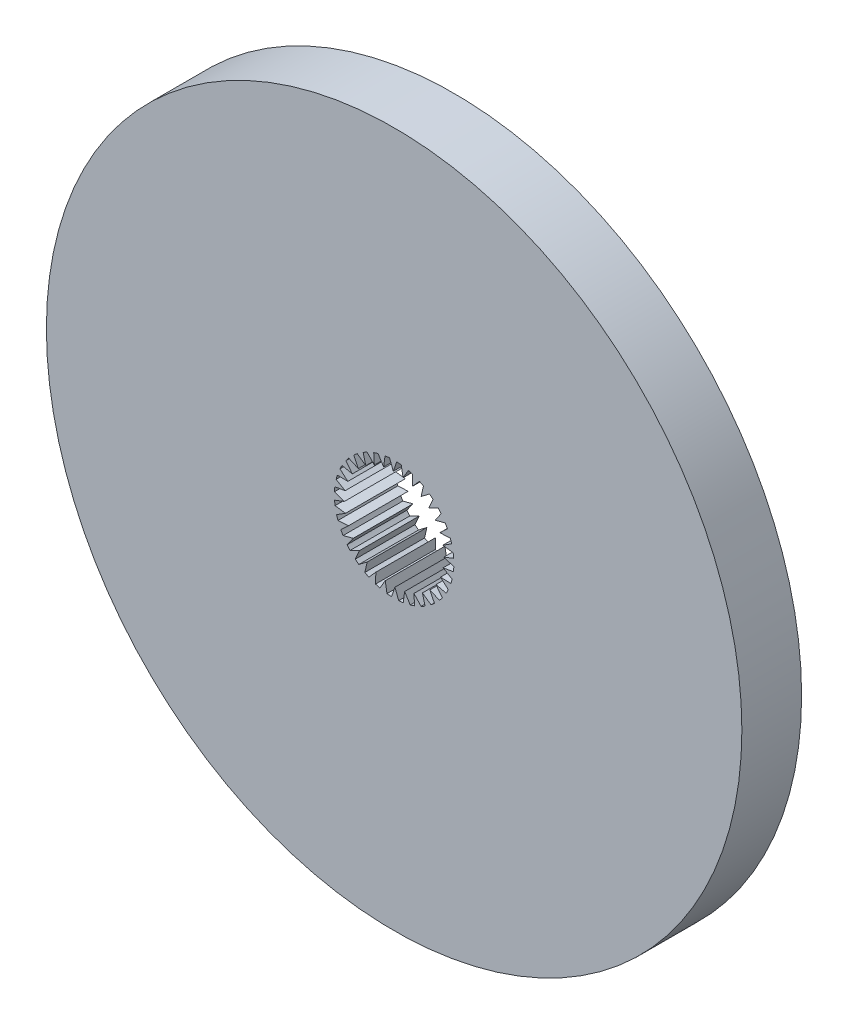
from build123d import *

# Parameters (mm, degrees)
SKETCH1_R          = 17.4625
EXTRUDE1_DEPTH     = 3
CUT_EXTRUDE2_DEPTH = 3


with BuildPart() as part:
    # Sketch1 → Extrude1 (new body)
    with BuildSketch(Plane.XY):
        Circle(SKETCH1_R)
    extrude(amount=EXTRUDE1_DEPTH)

    # Sketch4 → Cut-Extrude2 (cut)
    with BuildSketch(Plane(origin=(0, 0, 0), x_dir=(-1, 0, 0), z_dir=(0, 0, -1))):
        with BuildLine():
            Line((2.991248958, -0.228975264), (2.499665549, -0.040891873))
            Line((2.499665549, -0.040891873), (2.997137961, 0.131011615))
            ThreePointArc((2.997137961, 0.131011615), (2.989964496, 0.245178122), (2.978443806, 0.358988154))
            Line((2.978443806, 0.358988154), (2.459612785, 0.44755441))
            Line((2.459612785, 0.44755441), (2.913989697, 0.713206874))
            ThreePointArc((2.913989697, 0.713206874), (2.884681288, 0.823780229), (2.851178729, 0.933155859))
            Line((2.851178729, 0.933155859), (2.325038481, 0.918801427))
            Line((2.325038481, 0.918801427), (2.718858444, 1.267993992))
            ThreePointArc((2.718858444, 1.267993992), (2.668541396, 1.370724924), (2.614344452, 1.471462907))
            Line((2.614344452, 1.471462907), (2.101114252, 1.354739421))
            Line((2.101114252, 1.354739421), (2.419242985, 1.774052812))
            ThreePointArc((2.419242985, 1.774052812), (2.349850954, 1.86499343), (2.277042384, 1.953222461))
            Line((2.277042384, 1.953222461), (1.796445381, 1.738615539))
            Line((1.796445381, 1.738615539), (2.026657375, 2.211935778))
            ThreePointArc((2.026657375, 2.211935778), (1.940857058, 2.287591283), (1.852234854, 2.359920771))
            Line((1.852234854, 2.359920771), (1.422740121, 2.055677637))
            Line((1.422740121, 2.055677637), (1.556188458, 2.564815292))
            ThreePointArc((1.556188458, 2.564815292), (1.457277114, 2.622278287), (1.356246978, 2.675928649))
            Line((1.356246978, 2.675928649), (0.994359756, 2.293741196))
            Line((0.994359756, 2.293741196), (1.025916092, 2.819130393))
            ThreePointArc((1.025916092, 2.819130393), (0.917694828, 2.856192606), (0.808139291, 2.88910209))
            Line((0.808139291, 2.88910209), (0.527766704, 2.443657567))
            Line((0.527766704, 2.443657567), (0.456218346, 2.965107894))
            ThreePointArc((0.456218346, 2.965107894), (0.342846044, 2.980345046), (0.228975264, 2.991248958))
            Line((0.228975264, 2.991248958), (0.040891873, 2.499665549))
            Line((0.040891873, 2.499665549), (-0.131011615, 2.997137961))
            ThreePointArc((-0.131011615, 2.997137961), (-0.245178122, 2.989964496), (-0.358988154, 2.978443806))
            Line((-0.358988154, 2.978443806), (-0.44755441, 2.459612785))
            Line((-0.44755441, 2.459612785), (-0.713206874, 2.913989697))
            ThreePointArc((-0.713206874, 2.913989697), (-0.823780229, 2.884681288), (-0.933155859, 2.851178729))
            Line((-0.933155859, 2.851178729), (-0.918801427, 2.325038481))
            Line((-0.918801427, 2.325038481), (-1.267993992, 2.718858444))
            ThreePointArc((-1.267993992, 2.718858444), (-1.370724924, 2.668541396), (-1.471462907, 2.614344452))
            Line((-1.471462907, 2.614344452), (-1.354739421, 2.101114252))
            Line((-1.354739421, 2.101114252), (-1.774052812, 2.419242985))
            ThreePointArc((-1.774052812, 2.419242985), (-1.86499343, 2.349850954), (-1.953222461, 2.277042384))
            Line((-1.953222461, 2.277042384), (-1.738615539, 1.796445381))
            Line((-1.738615539, 1.796445381), (-2.211935778, 2.026657375))
            ThreePointArc((-2.211935778, 2.026657375), (-2.287591283, 1.940857058), (-2.359920771, 1.852234854))
            Line((-2.359920771, 1.852234854), (-2.055677637, 1.422740121))
            Line((-2.055677637, 1.422740121), (-2.564815292, 1.556188458))
            ThreePointArc((-2.564815292, 1.556188458), (-2.622278287, 1.457277114), (-2.675928649, 1.356246978))
            Line((-2.675928649, 1.356246978), (-2.293741196, 0.994359756))
            Line((-2.293741196, 0.994359756), (-2.819130393, 1.025916092))
            ThreePointArc((-2.819130393, 1.025916092), (-2.856192606, 0.917694828), (-2.88910209, 0.808139291))
            Line((-2.88910209, 0.808139291), (-2.443657567, 0.527766704))
            Line((-2.443657567, 0.527766704), (-2.965107894, 0.456218346))
            ThreePointArc((-2.965107894, 0.456218346), (-2.980345046, 0.342846044), (-2.991248958, 0.228975264))
            Line((-2.991248958, 0.228975264), (-2.499665549, 0.040891873))
            Line((-2.499665549, 0.040891873), (-2.997137961, -0.131011615))
            ThreePointArc((-2.997137961, -0.131011615), (-2.989964496, -0.245178122), (-2.978443806, -0.358988154))
            Line((-2.978443806, -0.358988154), (-2.459612785, -0.44755441))
            Line((-2.459612785, -0.44755441), (-2.913989697, -0.713206874))
            ThreePointArc((-2.913989697, -0.713206874), (-2.884681288, -0.823780229), (-2.851178729, -0.933155859))
            Line((-2.851178729, -0.933155859), (-2.325038481, -0.918801427))
            Line((-2.325038481, -0.918801427), (-2.718858444, -1.267993992))
            ThreePointArc((-2.718858444, -1.267993992), (-2.668541396, -1.370724924), (-2.614344452, -1.471462907))
            Line((-2.614344452, -1.471462907), (-2.101114252, -1.354739421))
            Line((-2.101114252, -1.354739421), (-2.419242985, -1.774052812))
            ThreePointArc((-2.419242985, -1.774052812), (-2.349850954, -1.86499343), (-2.277042384, -1.953222461))
            Line((-2.277042384, -1.953222461), (-1.796445381, -1.738615539))
            Line((-1.796445381, -1.738615539), (-2.026657375, -2.211935778))
            ThreePointArc((-2.026657375, -2.211935778), (-1.940857058, -2.287591283), (-1.852234854, -2.359920771))
            Line((-1.852234854, -2.359920771), (-1.422740121, -2.055677637))
            Line((-1.422740121, -2.055677637), (-1.556188458, -2.564815292))
            ThreePointArc((-1.556188458, -2.564815292), (-1.457277114, -2.622278287), (-1.356246978, -2.675928649))
            Line((-1.356246978, -2.675928649), (-0.994359756, -2.293741196))
            Line((-0.994359756, -2.293741196), (-1.025916092, -2.819130393))
            ThreePointArc((-1.025916092, -2.819130393), (-0.917694828, -2.856192606), (-0.808139291, -2.88910209))
            Line((-0.808139291, -2.88910209), (-0.527766704, -2.443657567))
            Line((-0.527766704, -2.443657567), (-0.456218346, -2.965107894))
            ThreePointArc((-0.456218346, -2.965107894), (-0.342846044, -2.980345046), (-0.228975264, -2.991248958))
            Line((-0.228975264, -2.991248958), (-0.040891873, -2.499665549))
            Line((-0.040891873, -2.499665549), (0.131011615, -2.997137961))
            ThreePointArc((0.131011615, -2.997137961), (0.245178122, -2.989964496), (0.358988154, -2.978443806))
            Line((0.358988154, -2.978443806), (0.44755441, -2.459612785))
            Line((0.44755441, -2.459612785), (0.713206874, -2.913989697))
            ThreePointArc((0.713206874, -2.913989697), (0.823780229, -2.884681288), (0.933155859, -2.851178729))
            Line((0.933155859, -2.851178729), (0.918801427, -2.325038481))
            Line((0.918801427, -2.325038481), (1.267993992, -2.718858444))
            ThreePointArc((1.267993992, -2.718858444), (1.370724924, -2.668541396), (1.471462907, -2.614344452))
            Line((1.471462907, -2.614344452), (1.354739421, -2.101114252))
            Line((1.354739421, -2.101114252), (1.774052812, -2.419242985))
            ThreePointArc((1.774052812, -2.419242985), (1.86499343, -2.349850954), (1.953222461, -2.277042384))
            Line((1.953222461, -2.277042384), (1.738615539, -1.796445381))
            Line((1.738615539, -1.796445381), (2.211935778, -2.026657375))
            ThreePointArc((2.211935778, -2.026657375), (2.287591283, -1.940857058), (2.359920771, -1.852234854))
            Line((2.359920771, -1.852234854), (2.055677637, -1.422740121))
            Line((2.055677637, -1.422740121), (2.564815292, -1.556188458))
            ThreePointArc((2.564815292, -1.556188458), (2.622278287, -1.457277114), (2.675928649, -1.356246978))
            Line((2.675928649, -1.356246978), (2.293741196, -0.994359756))
            Line((2.293741196, -0.994359756), (2.819130393, -1.025916092))
            ThreePointArc((2.819130393, -1.025916092), (2.856192606, -0.917694828), (2.88910209, -0.808139291))
            Line((2.88910209, -0.808139291), (2.443657567, -0.527766704))
            Line((2.443657567, -0.527766704), (2.965107894, -0.456218346))
            ThreePointArc((2.965107894, -0.456218346), (2.980345046, -0.342846044), (2.991248958, -0.228975264))
        make_face()
    extrude(amount=-CUT_EXTRUDE2_DEPTH, mode=Mode.SUBTRACT)


solid = part.part
